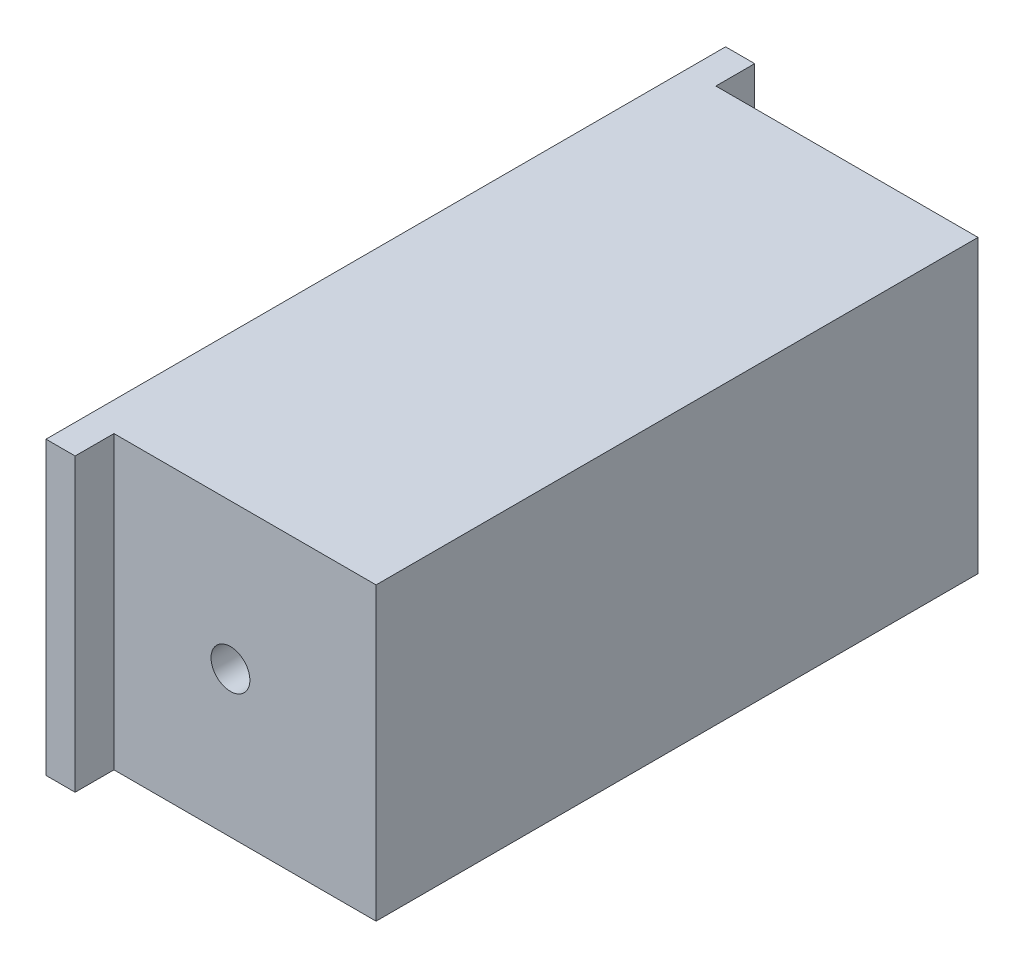
from build123d import *

# Parameters (mm, degrees)
SKETCH1_W           = 310
SKETCH1_H           = 150
BOSS_EXTRUDE1_DEPTH = 150
SKETCH2_R           = 10
CUT_EXTRUDE1_DEPTH  = 65
SKETCH3_W           = 15
SKETCH3_H           = 150
BOSS_EXTRUDE2_DEPTH = 20
CUT_EXTRUDE3_DEPTH  = 10


with BuildPart() as part:
    # Sketch1 → Boss-Extrude1 (new body)
    with BuildSketch(Plane(origin=(0, 0, 0), x_dir=(0, 0, -1), z_dir=(1, 0, 0))):
        Rectangle(SKETCH1_W, SKETCH1_H)
    extrude(amount=BOSS_EXTRUDE1_DEPTH)

    # Sketch2 → Cut-Extrude1 (cut)
    with BuildSketch(Plane(origin=(0, 0, -155), x_dir=(-1, 0, 0), z_dir=(0, 0, -1))):
        with Locations((-75, 0)):
            Circle(SKETCH2_R)
    cut_extrude1 = extrude(amount=-CUT_EXTRUDE1_DEPTH, mode=Mode.SUBTRACT)

    # Sketch3 → Boss-Extrude2 (add)
    with BuildSketch(Plane(origin=(0, 0, -155), x_dir=(-1, 0, 0), z_dir=(0, 0, -1))):
        with Locations((-7.5, 0)):
            Rectangle(SKETCH3_W, SKETCH3_H)
    boss_extrude2 = extrude(amount=BOSS_EXTRUDE2_DEPTH)

    # Mirror1: Cut-Extrude1, Boss-Extrude2 across plane
    add(cut_extrude1.mirror(Plane.XY), mode=Mode.SUBTRACT)
    add(boss_extrude2.mirror(Plane.XY))

    # Sketch4 → Cut-Extrude3 (cut)
    with BuildSketch(Plane.ZY):
        with BuildLine():
            add(Edge.make_bspline(
                [(-90.284150773, 1.560829234), (-90.315850363, 0.905350219), (-90.377550455, -0.37047434), (-90.666332247, -2.219996593), (-91.07370445, -3.957149902), (-91.656812473, -5.571324357), (-92.373460483, -7.072262128), (-93.231201359, -8.465663455), (-94.249828269, -9.732264112), (-95.405684612, -10.88357349), (-96.704892076, -11.895135741), (-98.128207069, -12.78266133), (-99.67854105, -13.532823806), (-101.356362691, -14.145698399), (-103.160598569, -14.610709338), (-105.088305643, -14.951335494), (-107.142234175, -15.150900395), (-108.553617299, -15.177362102), (-109.278222698, -15.190947567)],
                knots=[0, 0, 0, 0, 0.001967456, 0.003829458, 0.005607023, 0.007312554, 0.008967179, 0.010589351, 0.01220948, 0.01383205, 0.015472699, 0.01713833, 0.018855271, 0.020630114, 0.022488167, 0.024437568, 0.026497712, 0.028671329, 0.028671329, 0.028671329, 0.028671329], degree=3))
            add(Edge.make_bspline(
                [(-109.278222698, -15.190947567), (-110.128088354, -15.174436714), (-111.779415059, -15.142355394), (-114.18111832, -14.887470578), (-116.432788381, -14.464564468), (-118.537837997, -13.864179515), (-120.491028423, -13.087330861), (-122.296160074, -12.141813841), (-123.943718898, -11.019971545), (-125.43817551, -9.732707262), (-126.758304472, -8.274446125), (-127.915525768, -6.673419194), (-128.894153294, -4.920842875), (-129.67174684, -3.015221966), (-130.296739086, -0.968958379), (-130.735474399, 1.225421133), (-131.000029803, 3.566853818), (-131.030926373, 5.175122037), (-131.046807656, 6.001795063)],
                knots=[0, 0, 0, 0, 0.00254916, 0.00495313, 0.007235817, 0.009414611, 0.011509492, 0.013531125, 0.015515494, 0.017476343, 0.019434239, 0.021402913, 0.023391, 0.02544068, 0.027565865, 0.02980056, 0.032144762, 0.034624165, 0.034624165, 0.034624165, 0.034624165], degree=3))
            add(Edge.make_bspline(
                [(-131.046807656, 6.001795063), (-131.027437484, 6.784837279), (-130.989514087, 8.317896515), (-130.720421416, 10.559478656), (-130.254705146, 12.6783109), (-129.62319161, 14.682514101), (-128.786436486, 16.561088787), (-127.77064122, 18.320539869), (-126.578602877, 19.967602474), (-125.197539836, 21.468345712), (-123.675797569, 22.834056953), (-122.009856983, 24.013519243), (-120.223071956, 25.015987119), (-118.315474891, 25.84046844), (-116.276887448, 26.464846455), (-114.118931043, 26.915435755), (-111.839507165, 27.204072611), (-110.276655441, 27.232418028), (-109.478895024, 27.246886996)],
                knots=[0, 0, 0, 0, 0.002348955, 0.004598842, 0.006760308, 0.008849056, 0.010891891, 0.012916684, 0.014934095, 0.016978271, 0.019023712, 0.021057284, 0.023088608, 0.025159918, 0.027279329, 0.029473078, 0.031767324, 0.034159534, 0.034159534, 0.034159534, 0.034159534], degree=3))
            add(Edge.make_bspline(
                [(-109.478895024, 27.246886996), (-108.94056134, 27.238906689), (-107.876819843, 27.22313769), (-106.313077907, 27.086526883), (-104.799216322, 26.883029825), (-103.339966088, 26.574050301), (-101.923365294, 26.181758617), (-100.542646379, 25.700144125), (-99.201436997, 25.118659435), (-98.340087324, 24.658617431), (-97.909699171, 24.428749545)],
                knots=[0, 0, 0, 0, 0.001614693, 0.003190616, 0.004705834, 0.006194546, 0.007661494, 0.009112923, 0.01057821, 0.012041547, 0.012041547, 0.012041547, 0.012041547], degree=3))
            Line((-97.909699171, 24.428749545), (-97.133184517, 26.662319785))
            Line((-97.133184517, 26.662319785), (-90.284150773, 26.662319785))
            Line((-90.284150773, 26.662319785), (-90.284150773, 10.495110195))
            Line((-90.284150773, 10.495110195), (-97.543254053, 10.495110195))
            add(Edge.make_bspline(
                [(-97.543254053, 10.495110195), (-97.639426634, 10.943583758), (-97.826264529, 11.814849313), (-98.142121961, 13.070221727), (-98.510390315, 14.225528197), (-98.913395662, 15.285064819), (-99.340228097, 16.256790932), (-99.829589969, 17.12092684), (-100.325051599, 17.907089966), (-100.886997842, 18.581073777), (-101.469105764, 19.186204533), (-102.116817658, 19.693969314), (-102.805647079, 20.131380028), (-103.541369924, 20.493635393), (-104.331529977, 20.762535151), (-105.165867155, 20.965711222), (-106.052935975, 21.0758245), (-106.657578273, 21.094856676), (-106.966128504, 21.104568836)],
                knots=[0, 0, 0, 0, 0.001375989, 0.002673183, 0.003881761, 0.005011187, 0.006073367, 0.007061477, 0.007988329, 0.008856357, 0.009689252, 0.010502727, 0.011318446, 0.012133977, 0.012956248, 0.013817541, 0.014706023, 0.015631889, 0.015631889, 0.015631889, 0.015631889], degree=3))
            add(Edge.make_bspline(
                [(-106.966128504, 21.104568836), (-107.321615636, 21.095731073), (-108.013454707, 21.078531267), (-109.013538022, 20.91034793), (-109.941557422, 20.63129778), (-110.792375198, 20.23597494), (-111.571745763, 19.735433867), (-112.267433921, 19.113629627), (-112.888469055, 18.385220414), (-113.434947798, 17.542862952), (-113.906638758, 16.577800096), (-114.31432422, 15.484851765), (-114.649778318, 14.257113579), (-114.924556453, 12.897996734), (-115.152649981, 11.407863729), (-115.30579778, 9.782440838), (-115.388882772, 8.023939652), (-115.403981604, 6.807480204), (-115.411815974, 6.176292738)],
                knots=[0, 0, 0, 0, 0.001065722, 0.002074079, 0.003031791, 0.003964742, 0.004879524, 0.005800444, 0.006753416, 0.00774318, 0.008804501, 0.009969657, 0.01123765, 0.012618526, 0.014127628, 0.015758038, 0.017513909, 0.01940753, 0.01940753, 0.01940753, 0.01940753], degree=3))
            add(Edge.make_bspline(
                [(-115.411815974, 6.176292738), (-115.404908848, 5.524715125), (-115.391580023, 4.267352249), (-115.296110731, 2.453959768), (-115.140279479, 0.780100662), (-114.929572365, -0.753485839), (-114.643457433, -2.14394699), (-114.293807505, -3.391810428), (-113.893590957, -4.50466662), (-113.407046173, -5.47730592), (-112.859354803, -6.328573506), (-112.216893148, -7.051678), (-111.513357003, -7.681042355), (-110.712557227, -8.178649073), (-109.844626249, -8.580594899), (-108.888186862, -8.839581582), (-107.863381872, -9.027036485), (-107.150293031, -9.041287308), (-106.782905945, -9.048629407)],
                knots=[0, 0, 0, 0, 0.001954686, 0.003771997, 0.005445834, 0.006996828, 0.008413648, 0.009700797, 0.010882303, 0.011955321, 0.012957165, 0.013909257, 0.014849037, 0.015778513, 0.016727322, 0.017707659, 0.018743277, 0.019843858, 0.019843858, 0.019843858, 0.019843858], degree=3))
            add(Edge.make_bspline(
                [(-106.782905945, -9.048629407), (-106.444943456, -9.041664664), (-105.780546524, -9.027972749), (-104.809424258, -8.877987832), (-103.879616687, -8.668280471), (-102.998535993, -8.349974615), (-102.171282763, -7.936990744), (-101.383323442, -7.445961638), (-100.650800266, -6.855293639), (-99.961197754, -6.185935697), (-99.336522839, -5.434827795), (-98.774026974, -4.622596863), (-98.29462842, -3.742972962), (-97.882048382, -2.803490925), (-97.543140316, -1.802203359), (-97.282682252, -0.736269064), (-97.089002229, 0.389225042), (-97.020077888, 1.164637722), (-96.984861493, 1.560829234)],
                knots=[0, 0, 0, 0, 0.001013026, 0.001991498, 0.002941709, 0.003869013, 0.004793768, 0.00571121, 0.006648678, 0.007611187, 0.008589776, 0.00957476, 0.010570506, 0.011590161, 0.012649651, 0.013737326, 0.014879086, 0.016071941, 0.016071941, 0.016071941, 0.016071941], degree=3))
            Line((-96.984861493, 1.560829234), (-90.284150773, 1.560829234))
        make_face()
        with BuildLine():
            add(Edge.make_bspline(
                [(-71.045782102, 11.725318804), (-70.793263524, 12.03064904), (-70.303233336, 12.623163994), (-69.47952989, 13.396743462), (-68.625309837, 14.055121055), (-67.728401591, 14.596035603), (-66.790222506, 15.003505826), (-65.82328583, 15.30640022), (-64.81982089, 15.483996271), (-64.139267632, 15.508342027), (-63.795403706, 15.520643235)],
                knots=[0, 0, 0, 0, 0.001187674, 0.002304766, 0.003381468, 0.004418408, 0.005438063, 0.0064426, 0.007452428, 0.008483774, 0.008483774, 0.008483774, 0.008483774], degree=3))
            add(Edge.make_bspline(
                [(-63.795403706, 15.520643235), (-63.536301085, 15.516579961), (-63.031065162, 15.508656799), (-62.292299295, 15.418782348), (-61.590978256, 15.271694133), (-60.930779981, 15.06338334), (-60.310178665, 14.799204891), (-59.731156359, 14.474278573), (-59.190693013, 14.090372819), (-58.691502805, 13.651273291), (-58.239443542, 13.16949994), (-57.852410206, 12.636202625), (-57.517462436, 12.068373326), (-57.248868156, 11.455390298), (-57.037565806, 10.806574286), (-56.893123697, 10.118973669), (-56.789623272, 9.393084329), (-56.783655957, 8.89303189), (-56.78059717, 8.636709956)],
                knots=[0, 0, 0, 0, 0.000776956, 0.001515021, 0.002228597, 0.002923965, 0.003588433, 0.00424859, 0.004911911, 0.00557345, 0.006240205, 0.006889374, 0.007546294, 0.008214247, 0.008892996, 0.009589512, 0.01032001, 0.011088246, 0.011088246, 0.011088246, 0.011088246], degree=3))
            add(Edge.make_bspline(
                [(-56.78059717, 8.636709956), (-56.798062798, 8.207542443), (-56.831621127, 7.382943104), (-57.114513592, 6.209743179), (-57.587639949, 5.166763917), (-58.25688042, 4.281961488), (-59.074254192, 3.562845057), (-60.031695241, 3.047906407), (-61.11196746, 2.733075265), (-61.873727081, 2.696547032), (-62.268549049, 2.677614354)],
                knots=[0, 0, 0, 0, 0.001286144, 0.002471187, 0.003595479, 0.004698306, 0.005774336, 0.00683623, 0.007935219, 0.009117722, 0.009117722, 0.009117722, 0.009117722], degree=3))
            add(Edge.make_bspline(
                [(-62.268549049, 2.677614354), (-62.581388459, 2.691572293), (-63.190383516, 2.718743793), (-64.058404736, 2.962962953), (-64.8479466, 3.354813206), (-65.536564403, 3.895495134), (-66.123906985, 4.542312041), (-66.519788344, 5.303039826), (-66.797325264, 6.125251422), (-66.819991802, 6.706077732), (-66.831663251, 7.005156695)],
                knots=[0, 0, 0, 0, 0.000936859, 0.001823755, 0.002682171, 0.003565239, 0.004436898, 0.005280148, 0.006121772, 0.007015167, 0.007015167, 0.007015167, 0.007015167], degree=3))
            add(Edge.make_bspline(
                [(-66.831663251, 7.005156695), (-66.824944416, 7.209088298), (-66.811797307, 7.608132294), (-66.709474566, 8.188890709), (-66.518609158, 8.724691894), (-66.279120872, 9.230879568), (-65.944344411, 9.690294772), (-65.544425363, 10.116969039), (-65.065795986, 10.507183703), (-64.705778006, 10.723498204), (-64.519569057, 10.835380661)],
                knots=[0, 0, 0, 0, 0.000611738, 0.001197021, 0.001759895, 0.002313976, 0.002870799, 0.003457186, 0.004064929, 0.00471603, 0.00471603, 0.00471603, 0.00471603], degree=3))
            add(Edge.make_bspline(
                [(-64.519569057, 10.835380661), (-64.629634946, 10.869156064), (-64.845022732, 10.935251103), (-65.163477469, 11.001090643), (-65.466028769, 11.052508019), (-65.662322748, 11.053175637), (-65.75850255, 11.053502755)],
                knots=[0, 0, 0, 0, 0.000345157, 0.000675437, 0.000975274, 0.001263327, 0.001263327, 0.001263327, 0.001263327], degree=3))
            add(Edge.make_bspline(
                [(-65.75850255, 11.053502755), (-65.945149926, 11.047067457), (-66.312752094, 11.034393134), (-66.849998487, 10.925691739), (-67.358795163, 10.752246789), (-67.83571934, 10.505666149), (-68.27325593, 10.184429715), (-68.690908493, 9.805763601), (-69.073188649, 9.349822588), (-69.417130546, 8.825250837), (-69.735767317, 8.247322388), (-70.001584716, 7.611004954), (-70.228777226, 6.922010596), (-70.422463065, 6.185915677), (-70.556839803, 5.393914723), (-70.660847968, 4.552638275), (-70.735596065, 3.659031915), (-70.738782472, 3.04421899), (-70.740411171, 2.729963657)],
                knots=[0, 0, 0, 0, 0.000559482, 0.0011019, 0.001637185, 0.002167899, 0.002705453, 0.00326125, 0.003855567, 0.004484728, 0.005140663, 0.005832629, 0.006549982, 0.007316035, 0.008113587, 0.008957694, 0.009859063, 0.010801512, 0.010801512, 0.010801512, 0.010801512], degree=3))
            Line((-70.740411171, 2.729963657), (-70.740411171, -5.663374511))
            add(Edge.make_bspline(
                [(-70.740411171, -5.663374511), (-70.735095754, -5.928403278), (-70.725405669, -6.411554625), (-70.626287531, -7.065380962), (-70.460911575, -7.577507027), (-70.204076028, -7.9731146), (-69.799409515, -8.219103148), (-69.28157983, -8.372273075), (-68.62424676, -8.476886622), (-68.137976769, -8.485492775), (-67.869924417, -8.490236847)],
                knots=[0, 0, 0, 0, 0.000794731, 0.001448806, 0.00197585, 0.002401853, 0.002830173, 0.003362677, 0.004016752, 0.0048202, 0.0048202, 0.0048202, 0.0048202], degree=3))
            Line((-67.869924417, -8.490236847), (-66.273270691, -8.490236847))
            Line((-66.273270691, -8.490236847), (-66.273270691, -14.074162447))
            Line((-66.273270691, -14.074162447), (-87.492187972, -14.074162447))
            Line((-87.492187972, -14.074162447), (-87.492187972, -8.490236847))
            Line((-87.492187972, -8.490236847), (-86.296878899, -8.490236847))
            add(Edge.make_bspline(
                [(-86.296878899, -8.490236847), (-85.991161563, -8.485034556), (-85.432804563, -8.47553318), (-84.682107039, -8.375616001), (-84.096274051, -8.220518249), (-83.645170959, -7.97864004), (-83.346687743, -7.58457679), (-83.151553285, -7.069548787), (-83.049517394, -6.411757653), (-83.033711256, -5.928345526), (-83.025047492, -5.663374511)],
                knots=[0, 0, 0, 0, 0.000916777, 0.001674387, 0.002265236, 0.002730608, 0.003177541, 0.003713819, 0.004369348, 0.00516451, 0.00516451, 0.00516451, 0.00516451], degree=3))
            Line((-83.025047492, -5.663374511), (-83.025047492, 6.219917157))
            add(Edge.make_bspline(
                [(-83.025047492, 6.219917157), (-83.033808484, 6.467470632), (-83.049793976, 6.919161932), (-83.150493373, 7.531410932), (-83.3477661, 8.008114022), (-83.653850776, 8.362006898), (-84.098162367, 8.584708812), (-84.6845042, 8.718693841), (-85.433003876, 8.81424077), (-85.991123938, 8.817918011), (-86.296878899, 8.819932515)],
                knots=[0, 0, 0, 0, 0.000742897, 0.001355506, 0.001851598, 0.002271844, 0.002728632, 0.003314824, 0.004071277, 0.004987764, 0.004987764, 0.004987764, 0.004987764], degree=3))
            Line((-86.296878899, 8.819932515), (-87.492187972, 8.819932515))
            Line((-87.492187972, 8.819932515), (-87.492187972, 14.403858115))
            Line((-87.492187972, 14.403858115), (-71.045782102, 14.403858115))
            Line((-71.045782102, 14.403858115), (-71.045782102, 11.725318804))
        make_face()
        with BuildLine():
            add(Edge.make_bspline(
                [(-32.464346157, -10.496960109), (-32.784833862, -10.86543546), (-33.418016914, -11.593427028), (-34.503942142, -12.541476423), (-35.68114645, -13.346614127), (-36.937433732, -14.021243777), (-38.273014425, -14.546716491), (-39.677072975, -14.924426655), (-41.153286083, -15.14314933), (-42.159883207, -15.174820202), (-42.672460145, -15.190947567)],
                knots=[0, 0, 0, 0, 0.001463728, 0.002891866, 0.004310029, 0.005734752, 0.007160516, 0.008606032, 0.010087953, 0.011625539, 0.011625539, 0.011625539, 0.011625539], degree=3))
            add(Edge.make_bspline(
                [(-42.672460145, -15.190947567), (-43.097355632, -15.1855499), (-43.913907618, -15.175176817), (-45.092261845, -15.060064706), (-46.172409885, -14.872395861), (-47.158533296, -14.608031469), (-48.055527637, -14.286577123), (-48.845921405, -13.860966612), (-49.543460451, -13.371690544), (-50.151360073, -12.80123355), (-50.675806557, -12.135929264), (-51.108560444, -11.353839927), (-51.483938932, -10.471056988), (-51.784251348, -9.475230692), (-52.032107871, -8.374033954), (-52.186896334, -7.155876185), (-52.29629647, -5.831142778), (-52.307598833, -4.910382864), (-52.31345669, -4.433165903)],
                knots=[0, 0, 0, 0, 0.001274311, 0.002448934, 0.003547716, 0.004559351, 0.005509041, 0.00639898, 0.007243853, 0.008058591, 0.008891166, 0.009774235, 0.010731987, 0.011764108, 0.01289026, 0.014114296, 0.015444605, 0.016875912, 0.016875912, 0.016875912, 0.016875912], degree=3))
            Line((-52.31345669, -4.433165903), (-52.31345669, 6.080319017))
            add(Edge.make_bspline(
                [(-52.31345669, 6.080319017), (-52.3213943, 6.339597209), (-52.335950746, 6.815076477), (-52.446935814, 7.459030647), (-52.651712355, 7.961742578), (-52.965226361, 8.335573763), (-53.425893091, 8.57036304), (-54.027649151, 8.710130162), (-54.794335165, 8.803678326), (-55.361005778, 8.814166543), (-55.672536934, 8.819932515)],
                knots=[0, 0, 0, 0, 0.000777739, 0.001426263, 0.001949828, 0.002388942, 0.002857575, 0.003471301, 0.004236409, 0.005170624, 0.005170624, 0.005170624, 0.005170624], degree=3))
            Line((-55.672536934, 8.819932515), (-56.78059717, 8.819932515))
            Line((-56.78059717, 8.819932515), (-56.78059717, 14.403858115))
            Line((-56.78059717, 14.403858115), (-40.028820369, 14.403858115))
            Line((-40.028820369, 14.403858115), (-40.028820369, -3.866048459))
            add(Edge.make_bspline(
                [(-40.028820369, -3.866048459), (-40.020850266, -4.320406969), (-40.005977663, -5.168262255), (-39.846084725, -6.348725073), (-39.610796563, -7.354883938), (-39.243320885, -8.177327857), (-38.767967799, -8.829360886), (-38.158346107, -9.275213717), (-37.450652836, -9.567818449), (-36.937465904, -9.59358155), (-36.669740125, -9.607021967)],
                knots=[0, 0, 0, 0, 0.001362088, 0.002541723, 0.003568038, 0.004450417, 0.005228694, 0.005958097, 0.006690415, 0.007489159, 0.007489159, 0.007489159, 0.007489159], degree=3))
            add(Edge.make_bspline(
                [(-36.669740125, -9.607021967), (-36.381221129, -9.586018252), (-35.815628532, -9.544844028), (-35.021203998, -9.189506451), (-34.343399046, -8.605021843), (-33.778035823, -7.807846953), (-33.323657681, -6.828628432), (-32.994713239, -5.681211134), (-32.809457741, -4.378074424), (-32.78341926, -3.459493252), (-32.769717088, -2.976110316)],
                knots=[0, 0, 0, 0, 0.000862529, 0.001690842, 0.002557728, 0.003519288, 0.004600364, 0.005782062, 0.007087534, 0.008537545, 0.008537545, 0.008537545, 0.008537545], degree=3))
            Line((-32.769717088, -2.976110316), (-32.769717088, 6.080319017))
            add(Edge.make_bspline(
                [(-32.769717088, 6.080319017), (-32.773956589, 6.345580686), (-32.781647182, 6.826774013), (-32.891707442, 7.475008613), (-33.067864907, 7.98217431), (-33.367305212, 8.350459055), (-33.799279166, 8.574627233), (-34.359910821, 8.723477147), (-35.082805498, 8.799245172), (-35.616818412, 8.812589431), (-35.910675239, 8.819932515)],
                knots=[0, 0, 0, 0, 0.000794731, 0.001441668, 0.001966613, 0.002387764, 0.002829298, 0.003400961, 0.004121702, 0.005003606, 0.005003606, 0.005003606, 0.005003606], degree=3))
            Line((-35.910675239, 8.819932515), (-37.236857569, 8.819932515))
            Line((-37.236857569, 8.819932515), (-37.236857569, 14.403858115))
            Line((-37.236857569, 14.403858115), (-20.485080768, 14.403858115))
            Line((-20.485080768, 14.403858115), (-20.485080768, -5.750623349))
            add(Edge.make_bspline(
                [(-20.485080768, -5.750623349), (-20.481998806, -6.007382309), (-20.476350663, -6.477930529), (-20.351062321, -7.108676115), (-20.181336306, -7.614127359), (-19.891603101, -7.993728292), (-19.458919867, -8.226242675), (-18.907653823, -8.38528294), (-18.201702261, -8.472121743), (-17.681678646, -8.483820609), (-17.39647192, -8.490236847)],
                knots=[0, 0, 0, 0, 0.000768583, 0.00140854, 0.001922197, 0.002356868, 0.002802777, 0.003368551, 0.004073109, 0.004928859, 0.004928859, 0.004928859, 0.004928859], degree=3))
            Line((-17.39647192, -8.490236847), (-16.017940287, -8.490236847))
            Line((-16.017940287, -8.490236847), (-16.017940287, -14.074162447))
            Line((-16.017940287, -14.074162447), (-32.464346157, -14.074162447))
            Line((-32.464346157, -14.074162447), (-32.464346157, -10.496960109))
        make_face()
        with BuildLine():
            Line((-8.785011658, -14.519131518), (-13.225977487, -14.519131518))
            Line((-13.225977487, -14.519131518), (-13.225977487, -4.023096366))
            Line((-13.225977487, -4.023096366), (-7.642051887, -4.023096366))
            add(Edge.make_bspline(
                [(-7.642051887, -4.023096366), (-7.480496967, -4.465052055), (-7.168858759, -5.317581205), (-6.504721258, -6.466082222), (-5.713323163, -7.443134218), (-4.781463232, -8.24495807), (-3.708513698, -8.86102808), (-2.504150453, -9.296675896), (-1.168138978, -9.562852237), (-0.233019023, -9.591896464), (0.253967908, -9.607021967)],
                knots=[0, 0, 0, 0, 0.001409548, 0.002719008, 0.003959047, 0.005165638, 0.006385282, 0.007649518, 0.008992725, 0.01045239, 0.01045239, 0.01045239, 0.01045239], degree=3))
            add(Edge.make_bspline(
                [(0.253967908, -9.607021967), (0.568639991, -9.602951553), (1.150960779, -9.595418993), (1.953852876, -9.476697747), (2.627432546, -9.316698584), (3.170586919, -9.060722461), (3.59220571, -8.723385393), (3.880656865, -8.28990911), (4.063186398, -7.780093975), (4.076977212, -7.410012105), (4.084191874, -7.216403819)],
                knots=[0, 0, 0, 0, 0.000942934, 0.001744959, 0.002430626, 0.003012059, 0.003532636, 0.004028728, 0.004555772, 0.005133989, 0.005133989, 0.005133989, 0.005133989], degree=3))
            add(Edge.make_bspline(
                [(4.084191874, -7.216403819), (4.069941554, -7.077094609), (4.040182996, -6.786178961), (3.804122359, -6.376027698), (3.453768656, -5.974794134), (2.953629532, -5.599326949), (2.328064336, -5.223169246), (1.56334086, -4.861304397), (0.662470086, -4.504186435), (0.008153362, -4.292539981), (-0.339324187, -4.180144274)],
                knots=[0, 0, 0, 0, 0.000415967, 0.000868654, 0.001388206, 0.002009574, 0.002733792, 0.003576681, 0.004543924, 0.00563927, 0.00563927, 0.00563927, 0.00563927], degree=3))
            add(Edge.make_bspline(
                [(-0.339324187, -4.180144274), (-0.574748824, -4.104079198), (-1.019346031, -3.960431018), (-1.647314289, -3.765020058), (-2.191237081, -3.57611962), (-2.529150067, -3.464343208), (-2.686317916, -3.412354504)],
                knots=[0, 0, 0, 0, 0.000742231, 0.001401696, 0.001972826, 0.002469455, 0.002469455, 0.002469455, 0.002469455], degree=3))
            add(Edge.make_bspline(
                [(-2.686317916, -3.412354504), (-3.242716526, -3.234781904), (-4.309995423, -2.894163713), (-5.825908605, -2.362351473), (-7.191589387, -1.844969964), (-8.395358446, -1.317184834), (-9.453480788, -0.817085403), (-10.36001873, -0.324969897), (-11.103131677, 0.174322801), (-11.718606987, 0.659756531), (-12.215860348, 1.176813094), (-12.631035784, 1.727980466), (-12.998629373, 2.316110191), (-13.279752862, 2.9565469), (-13.512960314, 3.632113009), (-13.665035363, 4.353205909), (-13.763948084, 5.114931929), (-13.777452697, 5.637930399), (-13.784370047, 5.905821342)],
                knots=[0, 0, 0, 0, 0.001752051, 0.003360769, 0.004819052, 0.006131966, 0.007302695, 0.008329788, 0.009222715, 0.009985781, 0.010676866, 0.011367897, 0.012053231, 0.012752203, 0.013461284, 0.014193759, 0.014958867, 0.015762314, 0.015762314, 0.015762314, 0.015762314], degree=3))
            add(Edge.make_bspline(
                [(-13.784370047, 5.905821342), (-13.772694912, 6.264317507), (-13.749864674, 6.96534175), (-13.569062767, 7.987403844), (-13.283441302, 8.956780975), (-12.869969961, 9.868429217), (-12.339050303, 10.721948373), (-11.69944643, 11.523750882), (-10.929627197, 12.255806962), (-10.058177402, 12.937653211), (-9.081016583, 13.542047549), (-8.022994706, 14.077730914), (-6.879106868, 14.521949705), (-5.65333504, 14.887054355), (-4.344317203, 15.175240339), (-2.94992904, 15.370973979), (-1.47581499, 15.495360639), (-0.464640579, 15.512079583), (0.053295581, 15.520643235)],
                knots=[0, 0, 0, 0, 0.001074897, 0.002101916, 0.003103912, 0.004099657, 0.005094791, 0.006112653, 0.007167787, 0.0082743, 0.009426646, 0.010608924, 0.011827319, 0.013102585, 0.014442615, 0.01584431, 0.017323866, 0.018877508, 0.018877508, 0.018877508, 0.018877508], degree=3))
            add(Edge.make_bspline(
                [(0.053295581, 15.520643235), (0.527579579, 15.514724757), (1.46591278, 15.503015517), (2.855589377, 15.385952041), (4.213423091, 15.195301868), (5.543548387, 14.921311215), (6.853829184, 14.580136116), (8.150440903, 14.173105901), (9.424033948, 13.673404527), (10.254557252, 13.288398291), (10.671479106, 13.095125552)],
                knots=[0, 0, 0, 0, 0.001422584, 0.00281447, 0.004180381, 0.005533863, 0.006886108, 0.008240939, 0.00960841, 0.010986859, 0.010986859, 0.010986859, 0.010986859], degree=3))
            Line((10.671479106, 13.095125552), (11.596316784, 14.918626256))
            Line((11.596316784, 14.918626256), (15.810435635, 14.918626256))
            Line((15.810435635, 14.918626256), (15.810435635, 5.469577154))
            Line((15.810435635, 5.469577154), (11.343295155, 5.469577154))
            add(Edge.make_bspline(
                [(11.343295155, 5.469577154), (11.119648819, 5.81364709), (10.677991268, 6.49311758), (9.861458757, 7.389993283), (8.940231531, 8.167050576), (7.904036357, 8.801092367), (6.786867323, 9.30704496), (5.600800642, 9.675578584), (4.348694714, 9.900838779), (3.491851368, 9.924595834), (3.054655592, 9.936717635)],
                knots=[0, 0, 0, 0, 0.001229435, 0.002427892, 0.003623201, 0.004833824, 0.006059911, 0.007293456, 0.008551444, 0.009862037, 0.009862037, 0.009862037, 0.009862037], degree=3))
            add(Edge.make_bspline(
                [(3.054655592, 9.936717635), (2.760600364, 9.930732703), (2.20528726, 9.919430367), (1.417020635, 9.816979639), (0.726654549, 9.637527315), (0.137672878, 9.389695249), (-0.336530014, 9.077139602), (-0.683562906, 8.70254214), (-0.901835201, 8.264688472), (-0.928061956, 7.949820927), (-0.941341166, 7.790396232)],
                knots=[0, 0, 0, 0, 0.000881904, 0.001665445, 0.002378648, 0.003015624, 0.00357463, 0.0040688, 0.00453319, 0.005009476, 0.005009476, 0.005009476, 0.005009476], degree=3))
            add(Edge.make_bspline(
                [(-0.941341166, 7.790396232), (-0.926944952, 7.63696322), (-0.897489087, 7.323026376), (-0.676521162, 6.873927433), (-0.334219786, 6.450262488), (0.143282708, 6.047252428), (0.748818938, 5.658773653), (1.487135616, 5.286531237), (2.355485584, 4.931224958), (2.983552045, 4.718532267), (3.316402104, 4.605813663)],
                knots=[0, 0, 0, 0, 0.000459032, 0.000939217, 0.001473363, 0.002085661, 0.002804392, 0.003627727, 0.004562634, 0.005616721, 0.005616721, 0.005616721, 0.005616721], degree=3))
            add(Edge.make_bspline(
                [(3.316402104, 4.605813663), (3.639467816, 4.501860179), (4.207670139, 4.31902861), (4.773598757, 4.129282355), (5.017754436, 4.047421103)],
                knots=[0, 0, 0, 0, 0.001018123, 0.001790657, 0.001790657, 0.001790657, 0.001790657], degree=3))
            add(Edge.make_bspline(
                [(5.017754436, 4.047421103), (5.244482574, 3.980120944), (5.775674297, 3.822446261), (6.308822932, 3.671512874), (6.614408162, 3.585002264)],
                knots=[0, 0, 0, 0, 0.000709511, 0.001662282, 0.001662282, 0.001662282, 0.001662282], degree=3))
            add(Edge.make_bspline(
                [(6.614408162, 3.585002264), (7.013523991, 3.464986899), (7.785215351, 3.232936917), (8.89118672, 2.862424164), (9.916811785, 2.511291422), (10.847712981, 2.142053047), (11.696158883, 1.782206688), (12.466006224, 1.442424726), (13.138239436, 1.082542089), (13.548792786, 0.832550598), (13.742638186, 0.71451551)],
                knots=[0, 0, 0, 0, 0.001250218, 0.0024173, 0.003498974, 0.004501881, 0.00542069, 0.006264075, 0.007025193, 0.007706014, 0.007706014, 0.007706014, 0.007706014], degree=3))
            add(Edge.make_bspline(
                [(13.742638186, 0.71451551), (13.990163489, 0.544600998), (14.480681683, 0.207883263), (15.107530622, -0.429095563), (15.668799611, -1.126201843), (16.113157564, -1.918772258), (16.490531749, -2.764595751), (16.732856275, -3.67833863), (16.899996369, -4.636448691), (16.918021333, -5.293258268), (16.927220755, -5.628474976)],
                knots=[0, 0, 0, 0, 0.000898705, 0.001780955, 0.002669395, 0.003576279, 0.00449852, 0.005440525, 0.006404417, 0.007409144, 0.007409144, 0.007409144, 0.007409144], degree=3))
            add(Edge.make_bspline(
                [(16.927220755, -5.628474976), (16.918484692, -5.992684466), (16.901474084, -6.701862642), (16.730298814, -7.735964786), (16.450703214, -8.707492861), (16.06676523, -9.624784968), (15.563680439, -10.475530349), (14.953940843, -11.26877521), (14.237242139, -12.005531652), (13.403941838, -12.663042636), (12.483203961, -13.257724095), (11.478515912, -13.785005767), (10.382228578, -14.216478161), (9.209291925, -14.574590355), (7.954812148, -14.85238349), (6.617060645, -15.053564914), (5.194060741, -15.162441193), (4.218144308, -15.181285314), (3.717746757, -15.190947567)],
                knots=[0, 0, 0, 0, 0.001091866, 0.00212605, 0.003133954, 0.004119209, 0.005100826, 0.006090283, 0.007114482, 0.008175946, 0.009267394, 0.010399109, 0.011573732, 0.012796369, 0.014074884, 0.01542479, 0.016851462, 0.018352776, 0.018352776, 0.018352776, 0.018352776], degree=3))
            add(Edge.make_bspline(
                [(3.717746757, -15.190947567), (3.176502972, -15.183453745), (2.109599572, -15.168681871), (0.529959182, -15.024701097), (-1.001962686, -14.788654543), (-2.485339859, -14.47280864), (-3.892882517, -14.049808503), (-5.228873264, -13.56458177), (-6.477815205, -12.991626026), (-7.258422196, -12.541617651), (-7.642051887, -12.320460813)],
                knots=[0, 0, 0, 0, 0.001623415, 0.003200086, 0.00475363, 0.006271584, 0.007745754, 0.009159077, 0.010533212, 0.011861144, 0.011861144, 0.011861144, 0.011861144], degree=3))
            Line((-7.642051887, -12.320460813), (-8.785011658, -14.519131518))
        make_face()
        with BuildLine():
            add(Edge.make_bspline(
                [(56.014699958, -5.593575441), (56.021531798, -5.864619588), (56.034046143, -6.361109527), (56.157530349, -7.033506807), (56.370196423, -7.563068708), (56.700690099, -7.967467962), (57.19754243, -8.212926195), (57.837099214, -8.376851117), (58.655540018, -8.47512469), (59.260099755, -8.484881813), (59.591902296, -8.490236847)],
                knots=[0, 0, 0, 0, 0.000812586, 0.001488469, 0.00203952, 0.002509855, 0.003017475, 0.003669452, 0.004487593, 0.005482842, 0.005482842, 0.005482842, 0.005482842], degree=3))
            Line((59.591902296, -8.490236847), (60.481840438, -8.490236847))
            Line((60.481840438, -8.490236847), (60.481840438, -14.074162447))
            Line((60.481840438, -14.074162447), (40.938100837, -14.074162447))
            Line((40.938100837, -14.074162447), (40.938100837, -8.490236847))
            Line((40.938100837, -8.490236847), (41.540117816, -8.490236847))
            add(Edge.make_bspline(
                [(41.540117816, -8.490236847), (41.744408206, -8.485534202), (42.115568847, -8.476990304), (42.616700603, -8.370780372), (43.016349548, -8.214192295), (43.325576263, -7.953336957), (43.51407019, -7.558005813), (43.649931485, -7.038893616), (43.717133665, -6.365824691), (43.725485531, -5.867005206), (43.730063637, -5.593575441)],
                knots=[0, 0, 0, 0, 0.000611738, 0.001111423, 0.001529581, 0.001888258, 0.002294223, 0.002819168, 0.003495557, 0.004316114, 0.004316114, 0.004316114, 0.004316114], degree=3))
            Line((43.730063637, -5.593575441), (43.730063637, 4.928634362))
            add(Edge.make_bspline(
                [(43.730063637, 4.928634362), (43.721971924, 5.324880314), (43.706843903, 6.065689754), (43.547682691, 7.096192633), (43.309068082, 7.975061374), (42.939541167, 8.695128425), (42.456368788, 9.253368857), (41.871236201, 9.667748934), (41.163068608, 9.894637616), (40.660446841, 9.922252242), (40.397158044, 9.936717635)],
                knots=[0, 0, 0, 0, 0.001187738, 0.00222056, 0.003120619, 0.003908955, 0.004626308, 0.005316071, 0.006033424, 0.00682258, 0.00682258, 0.00682258, 0.00682258], degree=3))
            add(Edge.make_bspline(
                [(40.397158044, 9.936717635), (40.106402327, 9.917110238), (39.543308393, 9.879137448), (38.746965185, 9.56425999), (38.060028229, 9.038430613), (37.487269384, 8.317428422), (37.027214375, 7.437463754), (36.696889494, 6.411280809), (36.510754777, 5.246538158), (36.484668974, 4.426184325), (36.470960357, 3.995071801)],
                knots=[0, 0, 0, 0, 0.000870086, 0.001685057, 0.002526138, 0.003437752, 0.004425207, 0.005490215, 0.006657786, 0.007950954, 0.007950954, 0.007950954, 0.007950954], degree=3))
            Line((36.470960357, 3.995071801), (36.470960357, -5.593575441))
            add(Edge.make_bspline(
                [(36.470960357, -5.593575441), (36.474197308, -5.861353042), (36.480095018, -6.349242473), (36.562815379, -7.012832097), (36.701631993, -7.530494712), (36.904239142, -7.932816178), (37.229268308, -8.191953805), (37.63179572, -8.376459051), (38.144696169, -8.474243405), (38.518049218, -8.484587011), (38.721980364, -8.490236847)],
                knots=[0, 0, 0, 0, 0.000803116, 0.001463273, 0.001998984, 0.002409146, 0.002786743, 0.003220011, 0.003728231, 0.004339969, 0.004339969, 0.004339969, 0.004339969], degree=3))
            Line((38.721980364, -8.490236847), (39.262923157, -8.490236847))
            Line((39.262923157, -8.490236847), (39.262923157, -14.074162447))
            Line((39.262923157, -14.074162447), (19.719183555, -14.074162447))
            Line((19.719183555, -14.074162447), (19.719183555, -8.490236847))
            Line((19.719183555, -8.490236847), (20.914492629, -8.490236847))
            add(Edge.make_bspline(
                [(20.914492629, -8.490236847), (21.217183809, -8.484700435), (21.76953542, -8.474597577), (22.516575046, -8.378162972), (23.100002077, -8.20937392), (23.55822234, -7.963796357), (23.853939623, -7.555409728), (24.064262992, -7.034341198), (24.16022224, -6.358695591), (24.177093864, -5.864138815), (24.186324036, -5.593575441)],
                knots=[0, 0, 0, 0, 0.000908059, 0.001657028, 0.002250384, 0.002727708, 0.003181486, 0.003729142, 0.004401864, 0.00521445, 0.00521445, 0.00521445, 0.00521445], degree=3))
            Line((24.186324036, -5.593575441), (24.186324036, 18.146833244))
            add(Edge.make_bspline(
                [(24.186324036, 18.146833244), (24.177120408, 18.370923188), (24.16024405, 18.781828757), (24.062701967, 19.346482501), (23.848450827, 19.780644382), (23.546081107, 20.119737916), (23.091932957, 20.311725255), (22.514261254, 20.457957636), (21.768412998, 20.536016022), (21.217022108, 20.54257667), (20.914492629, 20.546176275)],
                knots=[0, 0, 0, 0, 0.000673231, 0.001234479, 0.001702705, 0.002110074, 0.002566612, 0.003152805, 0.003899534, 0.0048073, 0.0048073, 0.0048073, 0.0048073], degree=3))
            Line((20.914492629, 20.546176275), (19.719183555, 20.546176275))
            Line((19.719183555, 20.546176275), (19.719183555, 26.130101876))
            Line((19.719183555, 26.130101876), (36.470960357, 26.130101876))
            Line((36.470960357, 26.130101876), (36.470960357, 10.765581591))
            add(Edge.make_bspline(
                [(36.470960357, 10.765581591), (36.793494724, 11.160622589), (37.420865933, 11.929028603), (38.488873488, 12.916894823), (39.602143586, 13.749540917), (40.788617728, 14.416544803), (42.06204901, 14.913587074), (43.425422736, 15.273619847), (44.889807835, 15.482608828), (45.898977166, 15.507736589), (46.417327832, 15.520643235)],
                knots=[0, 0, 0, 0, 0.00152835, 0.002972838, 0.004351398, 0.0056912, 0.007042431, 0.008441299, 0.009913324, 0.011467922, 0.011467922, 0.011467922, 0.011467922], degree=3))
            add(Edge.make_bspline(
                [(46.417327832, 15.520643235), (46.839228205, 15.514227227), (47.652434127, 15.501860479), (48.825382313, 15.399874933), (49.901814277, 15.217347741), (50.883814738, 14.96676695), (51.769089067, 14.647416728), (52.559204511, 14.251811238), (53.251819597, 13.779474921), (53.859410926, 13.231639529), (54.372395408, 12.585052444), (54.819484475, 11.847164957), (55.192808263, 11.001768556), (55.497501706, 10.051194737), (55.728444027, 8.996141555), (55.889784739, 7.835080445), (55.997238347, 6.570916415), (56.008733081, 5.690846579), (56.014699958, 5.234005293)],
                knots=[0, 0, 0, 0, 0.001265589, 0.002439402, 0.003528092, 0.004537505, 0.005475987, 0.006346117, 0.00718102, 0.007983899, 0.008790562, 0.009647957, 0.01056573, 0.011556263, 0.012637938, 0.013801492, 0.015070925, 0.016441176, 0.016441176, 0.016441176, 0.016441176], degree=3))
            Line((56.014699958, 5.234005293), (56.014699958, -5.593575441))
        make_face()
        with BuildLine():
            add(Edge.make_bspline(
                [(92.868608921, -4.023096366), (92.777132844, -4.47855302), (92.598292119, -5.368995648), (92.210883372, -6.647171229), (91.740792074, -7.834794852), (91.189928762, -8.940248283), (90.542189882, -9.945993555), (89.827754655, -10.878598542), (89.003831869, -11.695855239), (88.116119402, -12.447445626), (87.125730304, -13.090467796), (86.059561201, -13.666757425), (84.892353148, -14.126976161), (83.647999649, -14.529612686), (82.310514702, -14.814874306), (80.889615034, -15.036534753), (79.379467251, -15.167174954), (78.341927636, -15.182885086), (77.809459567, -15.190947567)],
                knots=[0, 0, 0, 0, 0.001393034, 0.002723457, 0.004000155, 0.005221452, 0.00642194, 0.007584316, 0.008738015, 0.009896455, 0.011067671, 0.012273758, 0.013526166, 0.014825822, 0.016193293, 0.017623456, 0.019138524, 0.020735773, 0.020735773, 0.020735773, 0.020735773], degree=3))
            add(Edge.make_bspline(
                [(77.809459567, -15.190947567), (77.201002875, -15.181435169), (76.01256272, -15.162855512), (74.279930792, -14.953544151), (72.642845919, -14.633441592), (71.098142495, -14.195686005), (69.660966378, -13.60323438), (68.315835474, -12.896390163), (67.070231939, -12.056101908), (65.935375758, -11.083829966), (64.915465609, -10.006021988), (64.026766938, -8.826133029), (63.272959877, -7.557033303), (62.660397472, -6.191802402), (62.177765308, -4.736608258), (61.841650722, -3.186529107), (61.638635776, -1.54772292), (61.612162629, -0.426129728), (61.598625558, 0.147398067)],
                knots=[0, 0, 0, 0, 0.001824523, 0.003563666, 0.00522685, 0.0068256, 0.008371284, 0.009881722, 0.011377219, 0.012868664, 0.014356123, 0.015820162, 0.017291049, 0.018774921, 0.020300678, 0.021882026, 0.023525874, 0.025246092, 0.025246092, 0.025246092, 0.025246092], degree=3))
            add(Edge.make_bspline(
                [(61.598625558, 0.147398067), (61.61214429, 0.718026893), (61.638578979, 1.833841278), (61.841799906, 3.463880599), (62.17716274, 5.005596094), (62.664208874, 6.456056121), (63.270987604, 7.823387986), (64.025552997, 9.098090731), (64.928064867, 10.271734804), (65.942592831, 11.365581275), (67.088865343, 12.335289878), (68.320701177, 13.200774837), (69.658542327, 13.917932258), (71.087859098, 14.499107155), (72.603957054, 14.969567298), (74.219266801, 15.281406949), (75.925073257, 15.493098649), (77.096241155, 15.511314353), (77.696036078, 15.520643235)],
                knots=[0, 0, 0, 0, 0.001711501, 0.00334669, 0.004919518, 0.006436996, 0.007928823, 0.00939971, 0.010869018, 0.012362834, 0.01386658, 0.015364747, 0.016871603, 0.018409213, 0.019987863, 0.021625377, 0.023338523, 0.025136887, 0.025136887, 0.025136887, 0.025136887], degree=3))
            add(Edge.make_bspline(
                [(77.696036078, 15.520643235), (78.284108414, 15.51049516), (79.428679721, 15.490743857), (81.091714573, 15.29228064), (82.653045194, 14.984864901), (84.109851588, 14.539471615), (85.459226503, 13.964277132), (86.700554662, 13.258285993), (87.844669229, 12.436957802), (88.874603307, 11.480850836), (89.796432411, 10.41183442), (90.596576719, 9.227465344), (91.25587174, 7.924383929), (91.80860182, 6.523294557), (92.236876144, 5.009318509), (92.535922807, 3.38528419), (92.722697375, 1.652433616), (92.744163636, 0.461984874), (92.755185432, -0.149247981)],
                knots=[0, 0, 0, 0, 0.001763484, 0.003432288, 0.005016762, 0.006531905, 0.007993733, 0.00940816, 0.010807845, 0.012209404, 0.013613786, 0.015034254, 0.01648584, 0.01798614, 0.019546529, 0.021197838, 0.022935054, 0.024768297, 0.024768297, 0.024768297, 0.024768297], degree=3))
            Line((92.755185432, -0.149247981), (92.755185432, -1.231133566))
            Line((92.755185432, -1.231133566), (73.883261879, -1.231133566))
            Line((73.883261879, -1.231133566), (73.883261879, -1.850600312))
            add(Edge.make_bspline(
                [(73.883261879, -1.850600312), (73.888483244, -2.153238606), (73.898639056, -2.741884945), (73.971478153, -3.597887906), (74.0759447, -4.40519557), (74.257506134, -5.151376088), (74.460678324, -5.849611464), (74.726045288, -6.487243049), (75.029478656, -7.07804168), (75.387773946, -7.609919412), (75.787250757, -8.083054637), (76.232647355, -8.489367743), (76.710618597, -8.843507896), (77.239835388, -9.120640502), (77.801660862, -9.339862944), (78.40085583, -9.500508064), (79.043174226, -9.583467062), (79.484430332, -9.599019344), (79.711484225, -9.607021967)],
                knots=[0, 0, 0, 0, 0.000907765, 0.001765648, 0.002576311, 0.003346675, 0.004067046, 0.004755649, 0.005415171, 0.006056436, 0.006675349, 0.007268128, 0.007861484, 0.008454776, 0.009054259, 0.009667985, 0.010310849, 0.010992285, 0.010992285, 0.010992285, 0.010992285], degree=3))
            add(Edge.make_bspline(
                [(79.711484225, -9.607021967), (80.091326871, -9.59229752), (80.82659919, -9.563794987), (81.876722281, -9.285046993), (82.817812739, -8.826783413), (83.644323801, -8.183662543), (84.347811584, -7.370530702), (84.91214708, -6.392999994), (85.368257624, -5.269554679), (85.543786306, -4.451414665), (85.635680291, -4.023096366)],
                knots=[0, 0, 0, 0, 0.001137586, 0.002202057, 0.003232185, 0.004258351, 0.005322072, 0.006436844, 0.007630911, 0.008942897, 0.008942897, 0.008942897, 0.008942897], degree=3))
            Line((85.635680291, -4.023096366), (92.868608921, -4.023096366))
        make_face()
        with BuildLine():
            Line((73.883261879, 4.352792034), (82.81754284, 4.352792034))
            Line((82.81754284, 4.352792034), (82.81754284, 4.745411803))
            add(Edge.make_bspline(
                [(82.81754284, 4.745411803), (82.807790699, 5.13947262), (82.789325284, 5.88561615), (82.554934134, 6.931006969), (82.196217099, 7.842202704), (81.669169955, 8.598200162), (81.016990741, 9.208345499), (80.220266631, 9.634672929), (79.302519009, 9.891230669), (78.648810373, 9.921093073), (78.306777941, 9.936717635)],
                knots=[0, 0, 0, 0, 0.001179926, 0.002234157, 0.003196588, 0.00409935, 0.00497619, 0.005850769, 0.006784373, 0.007808906, 0.007808906, 0.007808906, 0.007808906], degree=3))
            add(Edge.make_bspline(
                [(78.306777941, 9.936717635), (77.972888755, 9.92324778), (77.329880215, 9.897307343), (76.42921882, 9.60582911), (75.643438979, 9.144436947), (74.998220013, 8.487571962), (74.487602175, 7.671793542), (74.134321556, 6.69678251), (73.914415219, 5.575356825), (73.894036679, 4.77563242), (73.883261879, 4.352792034)],
                knots=[0, 0, 0, 0, 0.000998456, 0.001922841, 0.002807159, 0.003707895, 0.004656783, 0.005672848, 0.006802173, 0.008069206, 0.008069206, 0.008069206, 0.008069206], degree=3))
        make_face(mode=Mode.SUBTRACT)
        with BuildLine():
            add(Edge.make_bspline(
                [(111.548585031, 11.725318804), (111.801103609, 12.03064904), (112.291133798, 12.623163994), (113.114837243, 13.396743462), (113.969057296, 14.055121055), (114.865965543, 14.596035603), (115.804144627, 15.003505826), (116.771081304, 15.30640022), (117.774546243, 15.483996271), (118.455099502, 15.508342027), (118.798963428, 15.520643235)],
                knots=[0, 0, 0, 0, 0.001187674, 0.002304766, 0.003381468, 0.004418408, 0.005438063, 0.0064426, 0.007452428, 0.008483774, 0.008483774, 0.008483774, 0.008483774], degree=3))
            add(Edge.make_bspline(
                [(118.798963428, 15.520643235), (119.058066048, 15.516579961), (119.563301972, 15.508656799), (120.302067838, 15.418782348), (121.003388877, 15.271694133), (121.663587152, 15.06338334), (122.284188468, 14.799204891), (122.863210774, 14.474278573), (123.403674121, 14.090372819), (123.902864328, 13.651273291), (124.354923591, 13.16949994), (124.741956928, 12.636202625), (125.076904697, 12.068373326), (125.345498978, 11.455390298), (125.556801327, 10.806574286), (125.701243436, 10.118973669), (125.804743862, 9.393084329), (125.810711176, 8.89303189), (125.813769963, 8.636709956)],
                knots=[0, 0, 0, 0, 0.000776956, 0.001515021, 0.002228597, 0.002923965, 0.003588433, 0.00424859, 0.004911911, 0.00557345, 0.006240205, 0.006889374, 0.007546294, 0.008214247, 0.008892996, 0.009589512, 0.01032001, 0.011088246, 0.011088246, 0.011088246, 0.011088246], degree=3))
            add(Edge.make_bspline(
                [(125.813769963, 8.636709956), (125.796304336, 8.207542443), (125.762746006, 7.382943104), (125.479853541, 6.209743179), (125.006727184, 5.166763917), (124.337486713, 4.281961488), (123.520112942, 3.562845057), (122.562671893, 3.047906407), (121.482399673, 2.733075265), (120.720640052, 2.696547032), (120.325818084, 2.677614354)],
                knots=[0, 0, 0, 0, 0.001286144, 0.002471187, 0.003595479, 0.004698306, 0.005774336, 0.00683623, 0.007935219, 0.009117722, 0.009117722, 0.009117722, 0.009117722], degree=3))
            add(Edge.make_bspline(
                [(120.325818084, 2.677614354), (120.012978674, 2.691572293), (119.403983617, 2.718743793), (118.535962398, 2.962962953), (117.746420533, 3.354813206), (117.057802731, 3.895495134), (116.470460149, 4.542312041), (116.07457879, 5.303039826), (115.797041869, 6.125251422), (115.774375331, 6.706077732), (115.762703882, 7.005156695)],
                knots=[0, 0, 0, 0, 0.000936859, 0.001823755, 0.002682171, 0.003565239, 0.004436898, 0.005280148, 0.006121772, 0.007015167, 0.007015167, 0.007015167, 0.007015167], degree=3))
            add(Edge.make_bspline(
                [(115.762703882, 7.005156695), (115.769422718, 7.209088298), (115.782569826, 7.608132294), (115.884892567, 8.188890709), (116.075757975, 8.724691894), (116.315246261, 9.230879568), (116.650022722, 9.690294772), (117.049941771, 10.116969039), (117.528571148, 10.507183703), (117.888589127, 10.723498204), (118.074798076, 10.835380661)],
                knots=[0, 0, 0, 0, 0.000611738, 0.001197021, 0.001759895, 0.002313976, 0.002870799, 0.003457186, 0.004064929, 0.00471603, 0.00471603, 0.00471603, 0.00471603], degree=3))
            add(Edge.make_bspline(
                [(118.074798076, 10.835380661), (117.964732187, 10.869156064), (117.749344401, 10.935251103), (117.430889664, 11.001090643), (117.128338364, 11.052508019), (116.932044386, 11.053175637), (116.835864584, 11.053502755)],
                knots=[0, 0, 0, 0, 0.000345157, 0.000675437, 0.000975274, 0.001263327, 0.001263327, 0.001263327, 0.001263327], degree=3))
            add(Edge.make_bspline(
                [(116.835864584, 11.053502755), (116.649217207, 11.047067457), (116.281615039, 11.034393134), (115.744368646, 10.925691739), (115.235571971, 10.752246789), (114.758647793, 10.505666149), (114.321111203, 10.184429715), (113.90345864, 9.805763601), (113.521178485, 9.349822588), (113.177236587, 8.825250837), (112.858599817, 8.247322388), (112.592782417, 7.611004954), (112.365589907, 6.922010596), (112.171904068, 6.185915677), (112.03752733, 5.393914723), (111.933519165, 4.552638275), (111.858771069, 3.659031915), (111.855584661, 3.04421899), (111.853955962, 2.729963657)],
                knots=[0, 0, 0, 0, 0.000559482, 0.0011019, 0.001637185, 0.002167899, 0.002705453, 0.00326125, 0.003855567, 0.004484728, 0.005140663, 0.005832629, 0.006549982, 0.007316035, 0.008113587, 0.008957694, 0.009859063, 0.010801512, 0.010801512, 0.010801512, 0.010801512], degree=3))
            Line((111.853955962, 2.729963657), (111.853955962, -5.663374511))
            add(Edge.make_bspline(
                [(111.853955962, -5.663374511), (111.85927138, -5.928403278), (111.868961464, -6.411554625), (111.968079603, -7.065380962), (112.133455559, -7.577507027), (112.390291105, -7.9731146), (112.794957618, -8.219103148), (113.312787303, -8.372273075), (113.970120373, -8.476886622), (114.456390364, -8.485492775), (114.724442716, -8.490236847)],
                knots=[0, 0, 0, 0, 0.000794731, 0.001448806, 0.00197585, 0.002401853, 0.002830173, 0.003362677, 0.004016752, 0.0048202, 0.0048202, 0.0048202, 0.0048202], degree=3))
            Line((114.724442716, -8.490236847), (116.321096442, -8.490236847))
            Line((116.321096442, -8.490236847), (116.321096442, -14.074162447))
            Line((116.321096442, -14.074162447), (95.102179161, -14.074162447))
            Line((95.102179161, -14.074162447), (95.102179161, -8.490236847))
            Line((95.102179161, -8.490236847), (96.297488235, -8.490236847))
            add(Edge.make_bspline(
                [(96.297488235, -8.490236847), (96.603205571, -8.485034556), (97.16156257, -8.47553318), (97.912260094, -8.375616001), (98.498093083, -8.220518249), (98.949196174, -7.97864004), (99.24767939, -7.58457679), (99.442813848, -7.069548787), (99.544849739, -6.411757653), (99.560655877, -5.928345526), (99.569319641, -5.663374511)],
                knots=[0, 0, 0, 0, 0.000916777, 0.001674387, 0.002265236, 0.002730608, 0.003177541, 0.003713819, 0.004369348, 0.00516451, 0.00516451, 0.00516451, 0.00516451], degree=3))
            Line((99.569319641, -5.663374511), (99.569319641, 6.219917157))
            add(Edge.make_bspline(
                [(99.569319641, 6.219917157), (99.560558649, 6.467470632), (99.544573157, 6.919161932), (99.44387376, 7.531410932), (99.246601033, 8.008114022), (98.940516357, 8.362006898), (98.496204766, 8.584708812), (97.909862934, 8.718693841), (97.161363257, 8.81424077), (96.603243195, 8.817918011), (96.297488235, 8.819932515)],
                knots=[0, 0, 0, 0, 0.000742897, 0.001355506, 0.001851598, 0.002271844, 0.002728632, 0.003314824, 0.004071277, 0.004987764, 0.004987764, 0.004987764, 0.004987764], degree=3))
            Line((96.297488235, 8.819932515), (95.102179161, 8.819932515))
            Line((95.102179161, 8.819932515), (95.102179161, 14.403858115))
            Line((95.102179161, 14.403858115), (111.548585031, 14.403858115))
            Line((111.548585031, 14.403858115), (111.548585031, 11.725318804))
        make_face()
    extrude(amount=-CUT_EXTRUDE3_DEPTH, mode=Mode.SUBTRACT)


solid = part.part
